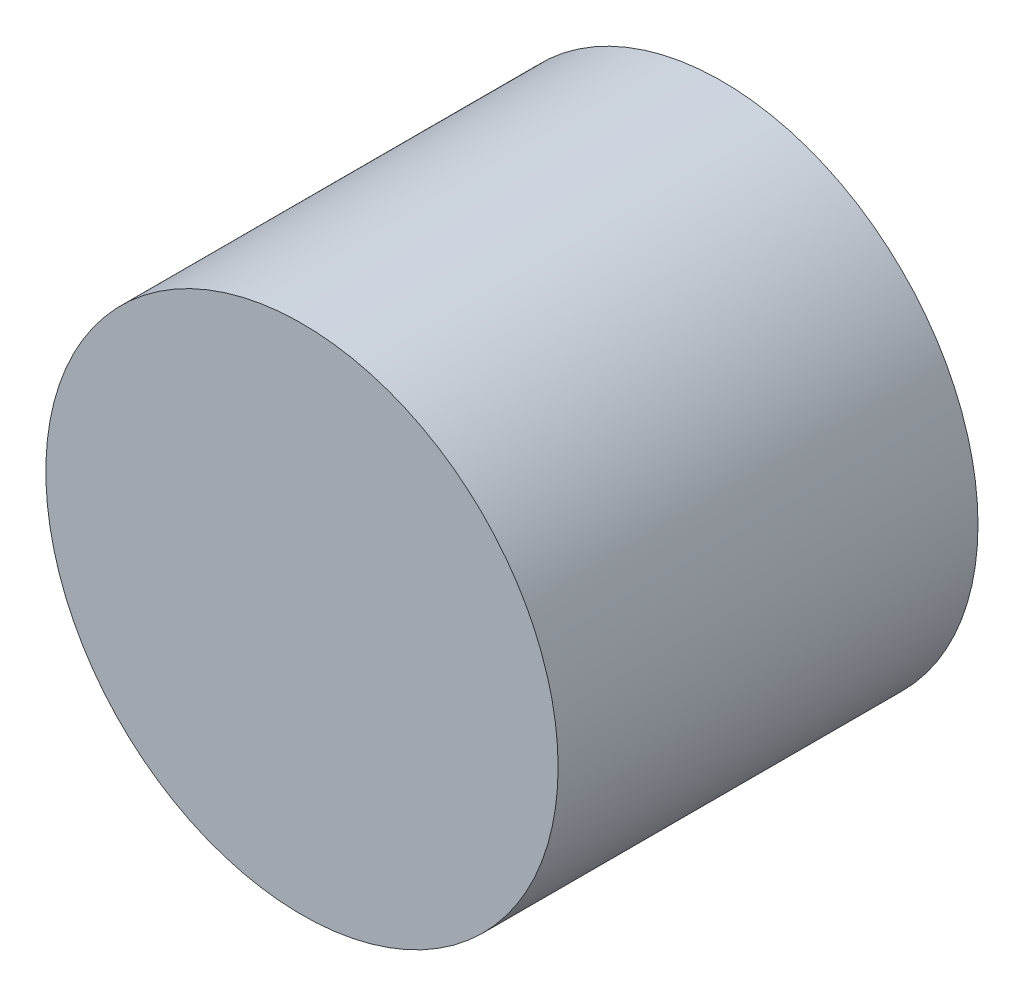
from build123d import *

# Parameters (mm, degrees)
SKETCH1_R           = 6.1
BOSS_EXTRUDE1_DEPTH = 10


with BuildPart() as part:
    # Sketch1 → Boss-Extrude1 (new body)
    with BuildSketch(Plane.XY):
        Circle(SKETCH1_R)
    extrude(amount=BOSS_EXTRUDE1_DEPTH)


solid = part.part
